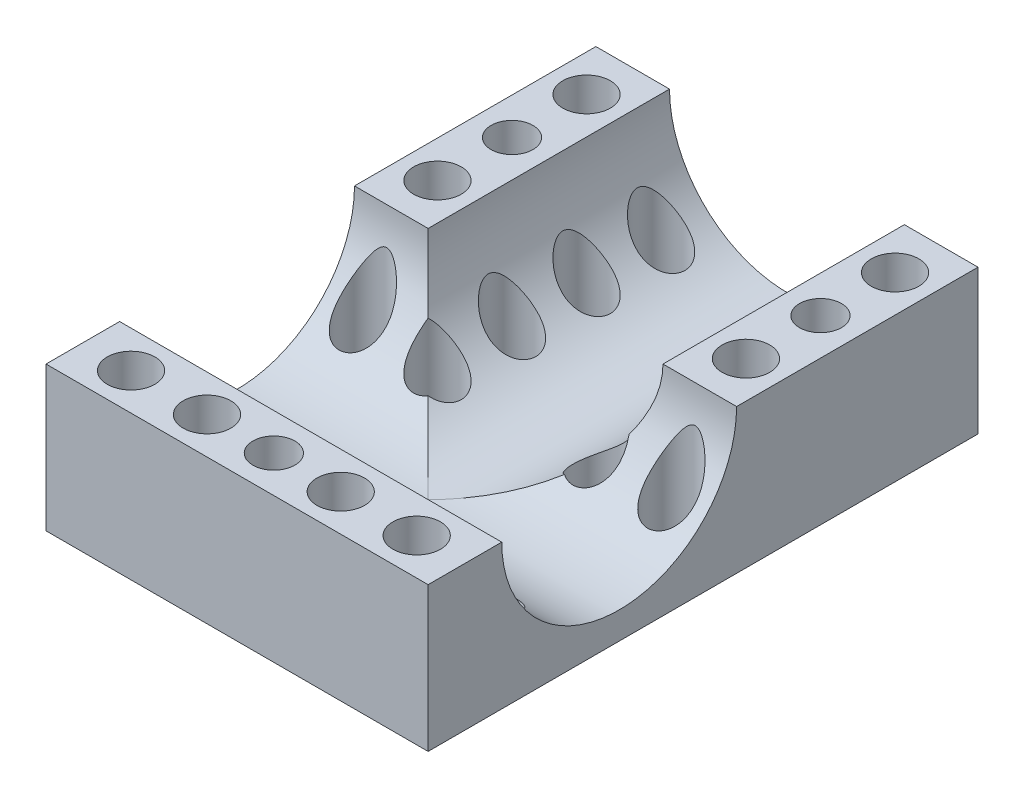
from build123d import *

# Parameters (mm, degrees)
EXTRUDE_1_DEPTH       = 15.5
CUT_EXTRUDE_1_DEPTH   = 42
CUT_EXTRUDE_2_DEPTH   = 38.5
M4X0_71_D             = 3.3
HOLE_WIZARD_1_4_201_D = 5.1054
HOLE_WIZARD_1_4_202_D = 5.1054
HOLE_WIZARD_1_4_203_D = 5.1054
SKETCH_31_R           = 2.25
CUT_EXTRUDE_4_DEPTH   = 16.5000001
HOLE_WIZARD_1_4_204_D = 5.1054


with BuildPart() as part:
    # Эскиз1 → Бобышка-Вытянуть1 (new body)
    with BuildSketch(Plane(origin=(0, 0, 0), x_dir=(1, 0, 0), z_dir=(0, 1, 0))):
        Polygon((0, 0), (8, 0), (33, 0), (41, 0), (41, 59), (0, 59), (0, 51), (0, 41), (0, 33), (0, 8), align=None)
    extrude(amount=EXTRUDE_1_DEPTH)

    # Эскиз4 → Вырез-Вытянуть1 (cut, through all)
    with BuildSketch(Plane.ZY):
        with BuildLine():
            Line((-33.1, 15.5), (-7.9, 15.5))
            ThreePointArc((-7.9, 15.5), (-20.5, 2.9), (-33.1, 15.5))
        make_face()
    extrude(amount=-CUT_EXTRUDE_1_DEPTH, mode=Mode.SUBTRACT)

    # Эскиз5 → Вырез-Вытянуть2 (cut)
    with BuildSketch(Plane(origin=(0, 0, -59), x_dir=(-1, 0, 0), z_dir=(0, 0, -1))):
        with BuildLine():
            Line((-33.1, 15.5), (-7.9, 15.5))
            ThreePointArc((-7.9, 15.5), (-20.5, 2.9), (-33.1, 15.5))
        make_face()
    extrude(amount=-CUT_EXTRUDE_2_DEPTH, mode=Mode.SUBTRACT)

    # Отверстие обработанное метчиком M4x0.71 (through all)
    with Locations(Plane(origin=(0, 15.5, 0), x_dir=(1, 0, 0), z_dir=(0, 1, 0))):
        with Locations((3.95, 46.05), (37.05, 46.05), (20.5, 3.95)):
            Hole(M4X0_71_D / 2)

    # Отверстие обработанное метчиком 1/4-201 (through all)
    with Locations(Plane(origin=(0, 15.5, 0), x_dir=(1, 0, 0), z_dir=(0, 1, 0))):
        with Locations((3.95, 54.05), (37.05, 54.05), (37.05, 38.05), (3.95, 38.05), (5.175, 3.95), (13.325, 3.95), (27.675, 3.95), (35.825, 3.95)):
            Hole(HOLE_WIZARD_1_4_201_D / 2)

    # Отверстие обработанное метчиком 1/4-202 (through all)
    with Locations(Plane(origin=(0, 15.5, 0), x_dir=(1, 0, 0), z_dir=(0, 1, 0))):
        with Locations((3.95, 30.05), (37.05, 30.05), (35.825, 11.95), (5.175, 11.95)):
            Hole(HOLE_WIZARD_1_4_202_D / 2)

    # Отверстие обработанное метчиком 1/4-203 (through all)
    with Locations(Plane(origin=(0, 15.5, 0), x_dir=(1, 0, 0), z_dir=(0, 1, 0))):
        with Locations((11.95, 54.05), (11.95, 46.05), (11.95, 38.05), (11.95, 30.05), (29.05, 54.05), (29.05, 46.05), (29.05, 38.05), (29.05, 30.05)):
            Hole(HOLE_WIZARD_1_4_203_D / 2)

    # Эскиз31 → Вырез-Вытянуть4 (cut, through all)
    with BuildSketch(Plane.XZ):
        with Locations((3.95, -46.05)):
            Circle(SKETCH_31_R)
        with Locations((37.05, -46.05)):
            Circle(SKETCH_31_R)
        with Locations((20.5, -3.95)):
            Circle(SKETCH_31_R)
    extrude(amount=-CUT_EXTRUDE_4_DEPTH, mode=Mode.SUBTRACT)

    # Отверстие обработанное метчиком 1/4-204 (through all)
    with Locations(Plane(origin=(0, 15.5, 0), x_dir=(1, 0, 0), z_dir=(0, 1, 0))):
        with Locations((27.675, 11.95), (13.325, 11.95), (20.5, 11.95)):
            Hole(HOLE_WIZARD_1_4_204_D / 2)


solid = part.part
